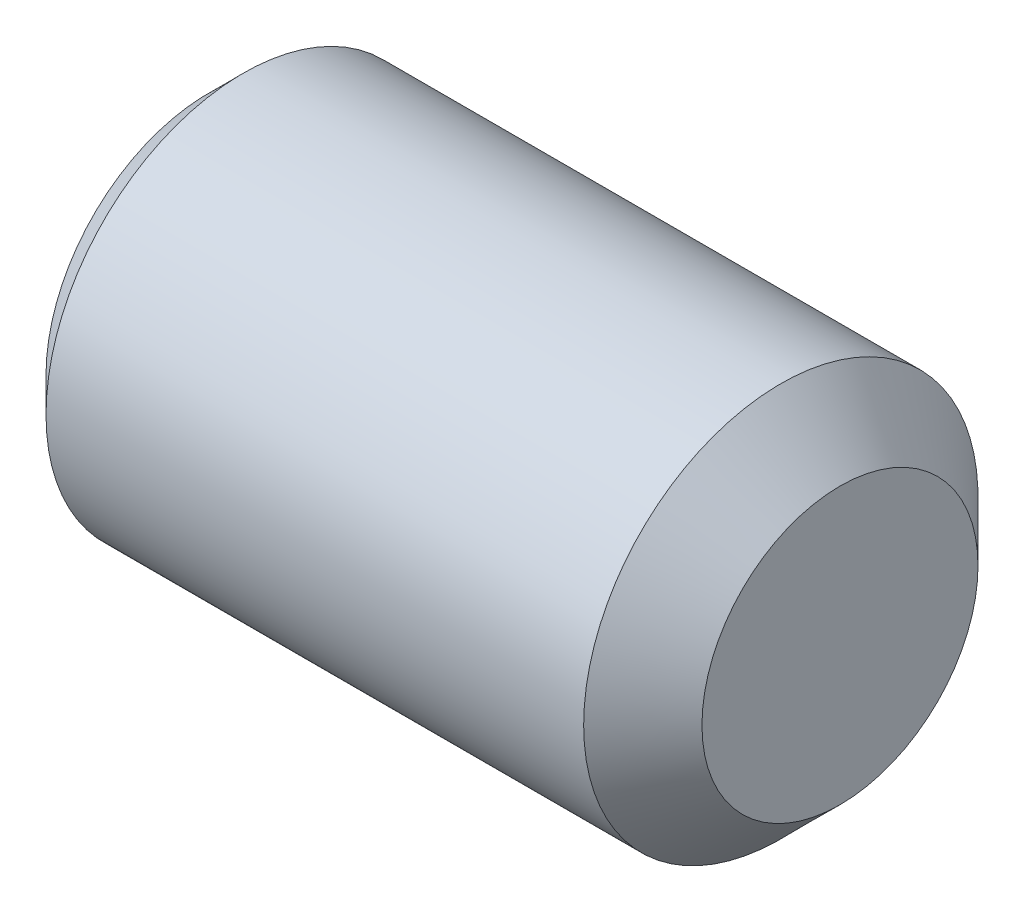
from build123d import *

# Parameters (mm, degrees)
HEXAGONSOCKET_DEPTH = 2


with BuildPart() as part:
    # Sketch1 → Base (revolve)
    with BuildSketch(Plane.XY):
        Polygon((0, 0), (8, 0), (8, 1.75), (7.25, 2.5), (0.433, 2.5), (0, 2.067), align=None)
    revolve(axis=Axis((-10.745014543, 0, 0), (1, 0, 0)))

    # Sketch2 → HexagonSocket (cut)
    with BuildSketch(Plane(origin=(0, -0.021932325, 0.010138848), x_dir=(0, 0, 1), z_dir=(-1, 0, 0))):
        Polygon((1.433236825, 0.021932325), (0.711548988, 1.271932325), (-0.731826685, 1.271932325), (-1.453514521, 0.021932325), (-0.731826685, -1.228067675), (0.711548988, -1.228067675), align=None)
    extrude(amount=-HEXAGONSOCKET_DEPTH, mode=Mode.SUBTRACT)

    # Sketch3 → Cut-Revolve1 (revolve, cut)
    with BuildSketch(Plane.XY):
        Polygon((2, 1.25), (2.721687837, 0), (2, 0), align=None)
    revolve(axis=Axis((-3.144113667, 0, 0), (1, 0, 0)), mode=Mode.SUBTRACT)


solid = part.part
